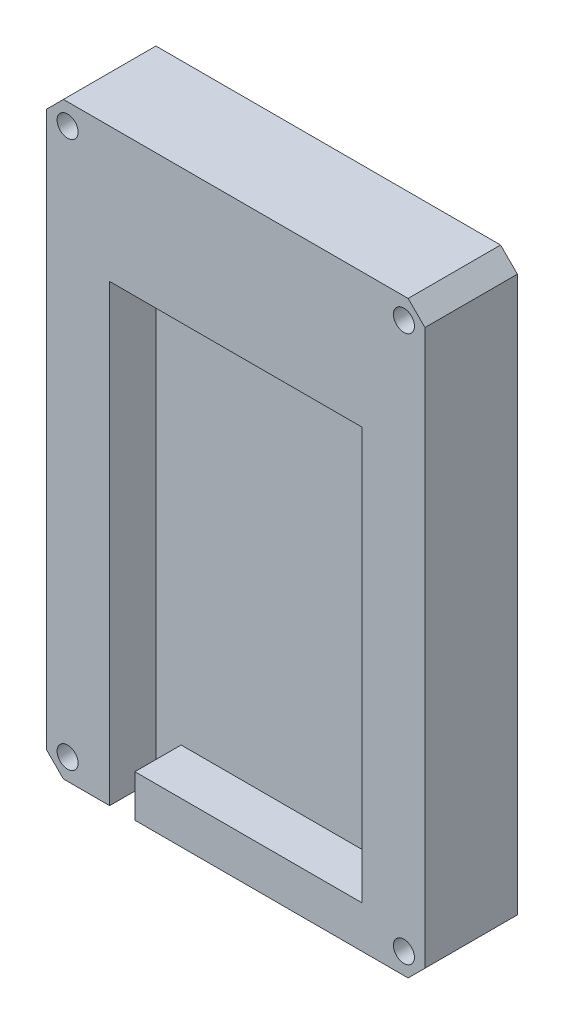
from build123d import *

# Parameters (mm, degrees)
BOSS_EXTRUDE1_DEPTH               = 5.5
SKETCH1_3_W                       = 45
SKETCH1_3_H                       = 70
BOSS_EXTRUDE2_DEPTH               = 5.5
TAP_DRILL_FOR_M3_TAP1_D           = 2.5
TAP_DRILL_FOR_M3_TAP1_CSINK_D     = 2.55
TAP_DRILL_FOR_M3_TAP1_CSINK_ANGLE = 90
CHAMFER1_SIZE                     = 2


with BuildPart() as part:
    # Sketch1 → Boss-Extrude1 (new body)
    with BuildSketch(Plane.XY):
        Polygon((-12, -29.5), (22.5, -29.5), (22.5, 40.5), (-22.5, 40.5), (-22.5, -29.5), (-15, -29.5), (-15, -24.5), (-15, 24.5), (15, 24.5), (15, -24.5), (-12, -24.5), align=None)
    extrude(amount=BOSS_EXTRUDE1_DEPTH)

    # Sketch1_3 → Boss-Extrude2 (add)
    with BuildSketch(Plane.XY):
        with Locations((0, 5.5)):
            Rectangle(SKETCH1_3_W, SKETCH1_3_H)
    extrude(amount=-BOSS_EXTRUDE2_DEPTH)

    # Tap Drill for M3 Tap1 (through all)
    with Locations(Plane(origin=(0, 0, -5.5), x_dir=(-1, 0, 0), z_dir=(0, 0, -1))):
        with Locations((20, 38), (-20, 38), (-20, -27), (20, -27)):
            CounterSinkHole(TAP_DRILL_FOR_M3_TAP1_D / 2, TAP_DRILL_FOR_M3_TAP1_CSINK_D / 2, counter_sink_angle=TAP_DRILL_FOR_M3_TAP1_CSINK_ANGLE)

    # Chamfer1
    chamfer1_edges = [part.edges().sort_by_distance(p)[0] for p in [
        (22.5, -29.5, 0),
        (22.5, 40.5, 0),
        (-22.5, 40.5, 0),
        (-22.5, -29.5, 0),
    ]]
    chamfer(chamfer1_edges, length=CHAMFER1_SIZE)


solid = part.part
